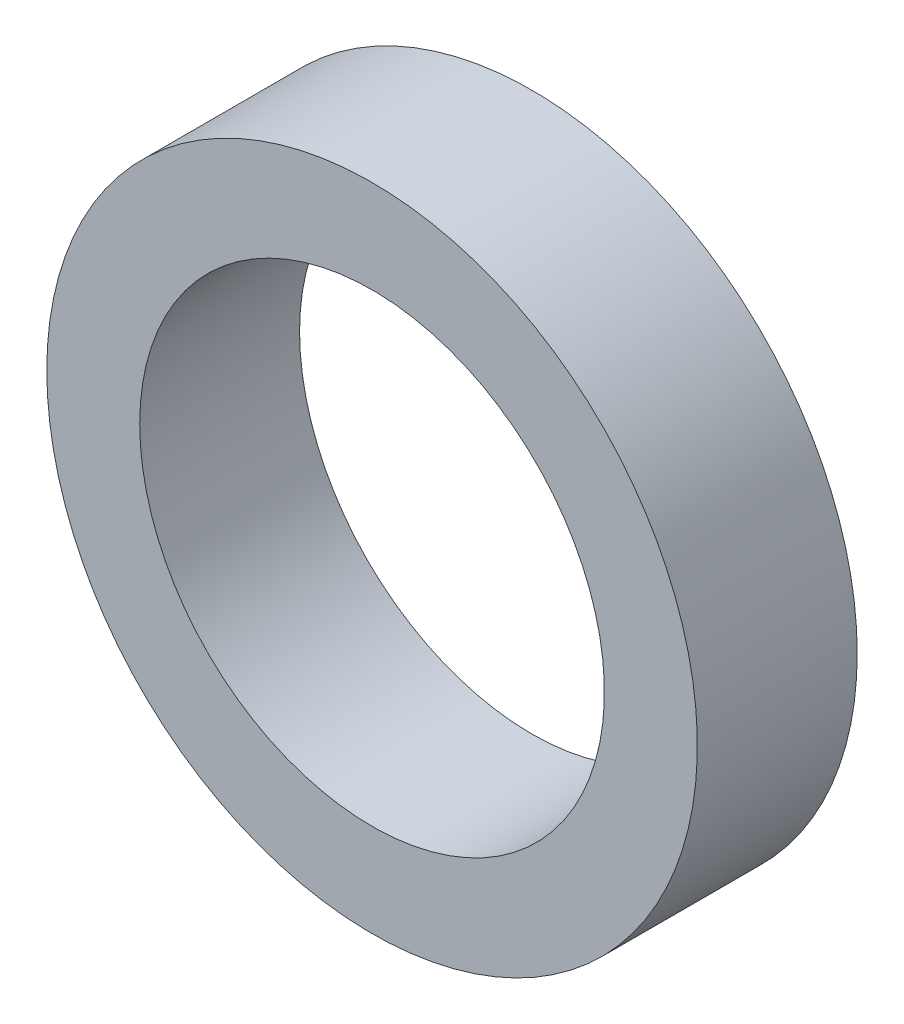
from build123d import *

# Parameters (mm, degrees)
SKETCH_1_R      = 17.5
SKETCH_1_R_2    = 12.5
EXTRUDE_1_DEPTH = 8.6


with BuildPart() as part:
    # Эскиз1 → Бобышка-Вытянуть1 (new body)
    with BuildSketch(Plane.XY):
        with Locations((0, -65)):
            Circle(SKETCH_1_R)
        with Locations((0, -65)):
            Circle(SKETCH_1_R_2, mode=Mode.SUBTRACT)
    extrude(amount=EXTRUDE_1_DEPTH)


solid = part.part
